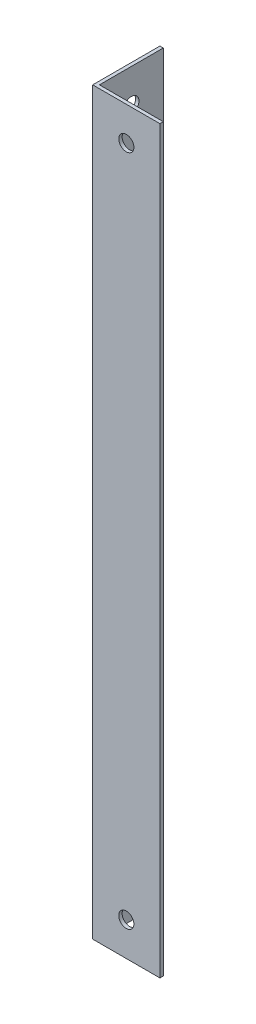
from build123d import *

# Parameters (mm, degrees)
EXTRUDE_1_DEPTH     = 220
SKETCH_2_R          = 4.25
CUT_EXTRUDE_1_DEPTH = 2
SKETCH_3_R          = 2.25
CUT_EXTRUDE_2_DEPTH = 2
SKETCH_4_R          = 2.25
CUT_EXTRUDE_3_DEPTH = 2
SKETCH_5_R          = 2.25
CUT_EXTRUDE_4_DEPTH = 2


with BuildPart() as part:
    # Эскиз1 → Бобышка-Вытянуть1 (new body)
    with BuildSketch(Plane(origin=(0, 0, 0), x_dir=(1, 0, 0), z_dir=(0, 1, 0))):
        Polygon((0, 0), (0, 20), (1, 20), (1, 1), (20, 1), (20, 0), align=None)
    extrude(amount=EXTRUDE_1_DEPTH)

    # Эскиз2 → Вырез-Вытянуть1 (cut, through all)
    with BuildSketch(Plane(origin=(1, 0, 0), x_dir=(0, 0, -1), z_dir=(1, 0, 0))):
        with Locations((10.5, 180)):
            Circle(SKETCH_2_R)
        with Locations((10.5, 120)):
            Circle(SKETCH_2_R)
        with Locations((10.5, 60)):
            Circle(SKETCH_2_R)
    extrude(amount=-CUT_EXTRUDE_1_DEPTH, mode=Mode.SUBTRACT)

    # Эскиз3 → Вырез-Вытянуть2 (cut, through all)
    with BuildSketch(Plane(origin=(1, 0, 0), x_dir=(0, 0, -1), z_dir=(1, 0, 0))):
        with Locations((10.5, 10)):
            Circle(SKETCH_3_R)
    extrude(amount=-CUT_EXTRUDE_2_DEPTH, mode=Mode.SUBTRACT)

    # Эскиз4 → Вырез-Вытянуть3 (cut, through all)
    with BuildSketch(Plane(origin=(1, 0, 0), x_dir=(0, 0, -1), z_dir=(1, 0, 0))):
        with Locations((10.5, 210)):
            Circle(SKETCH_4_R)
    extrude(amount=-CUT_EXTRUDE_3_DEPTH, mode=Mode.SUBTRACT)

    # Эскиз5 → Вырез-Вытянуть4 (cut, through all)
    with BuildSketch(Plane(origin=(0, 0, -1), x_dir=(-1, 0, 0), z_dir=(0, 0, -1))):
        with Locations((-10, 10)):
            Circle(SKETCH_5_R)
        with Locations((-10, 210)):
            Circle(SKETCH_5_R)
    extrude(amount=-CUT_EXTRUDE_4_DEPTH, mode=Mode.SUBTRACT)


solid = part.part
